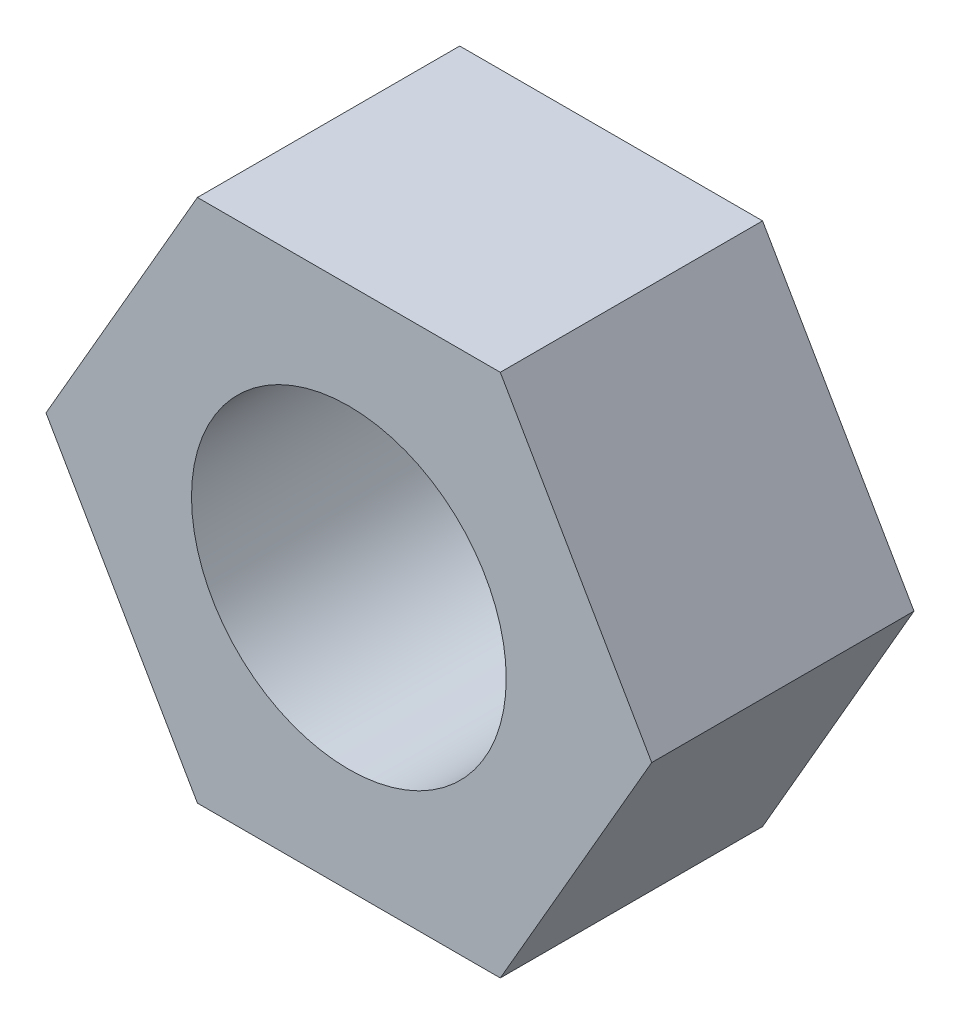
from build123d import *

# Parameters (mm, degrees)
ESBO_O1_R                = 3
RESSALTO_EXTRUS_O1_DEPTH = 5


with BuildPart() as part:
    # Esboço1 → Ressalto-extrusão1 (new body)
    with BuildSketch(Plane.XY):
        Polygon((2.886751346, 5), (-2.886751346, 5), (-5.773502692, 0), (-2.886751346, -5), (2.886751346, -5), (5.773502692, 0), align=None)
        Circle(ESBO_O1_R, mode=Mode.SUBTRACT)
    extrude(amount=RESSALTO_EXTRUS_O1_DEPTH)


solid = part.part
